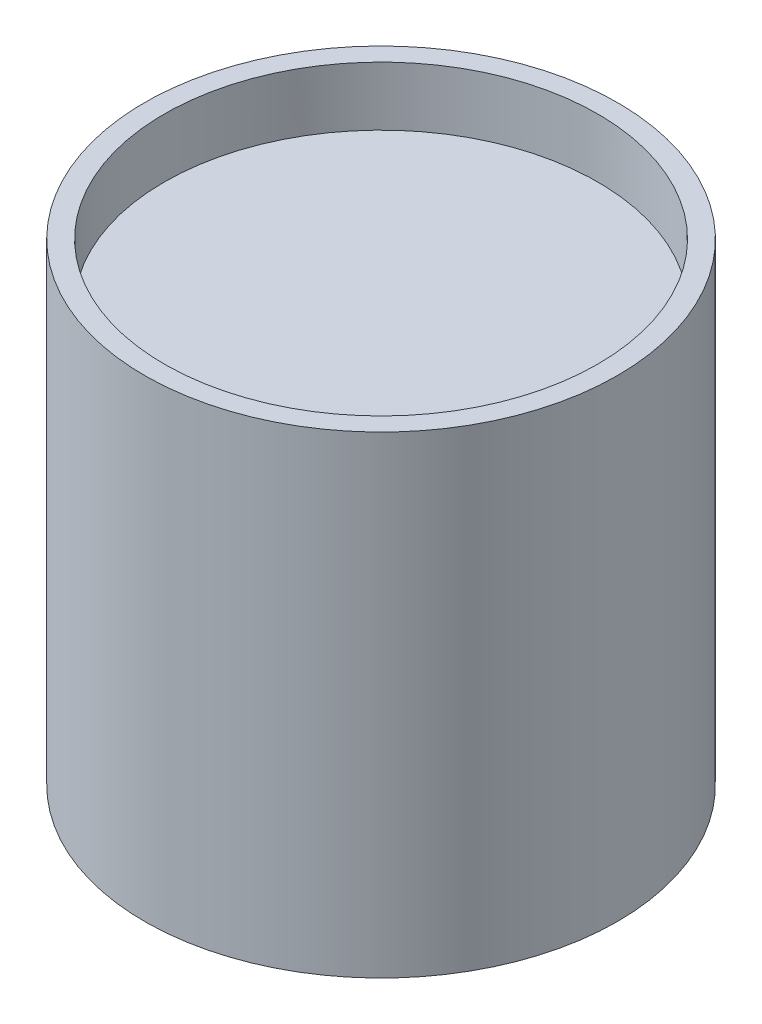
from build123d import *

# Parameters (mm, degrees)
SKETCH2_W = 34.925
SKETCH2_H = 63.5


with BuildPart() as part:
    # Sketch1 → Revolve1 (revolve)
    with BuildSketch(Plane.XY):
        Polygon((34.925, 76.2), (34.925, 3.175), (0, 3.175), (0, 0), (38.1, 0), (38.1, 76.2), align=None)
    revolve(axis=Axis((0, -1000, 0), (0, 1, 0)))

    # Sketch2 → Revolve2 (revolve)
    with BuildSketch(Plane.XY):
        with Locations((17.4625, 34.9504)):
            Rectangle(SKETCH2_W, SKETCH2_H)
    revolve(axis=Axis((0, 66.7004, 0), (0, -1, 0)))


solid = part.part
